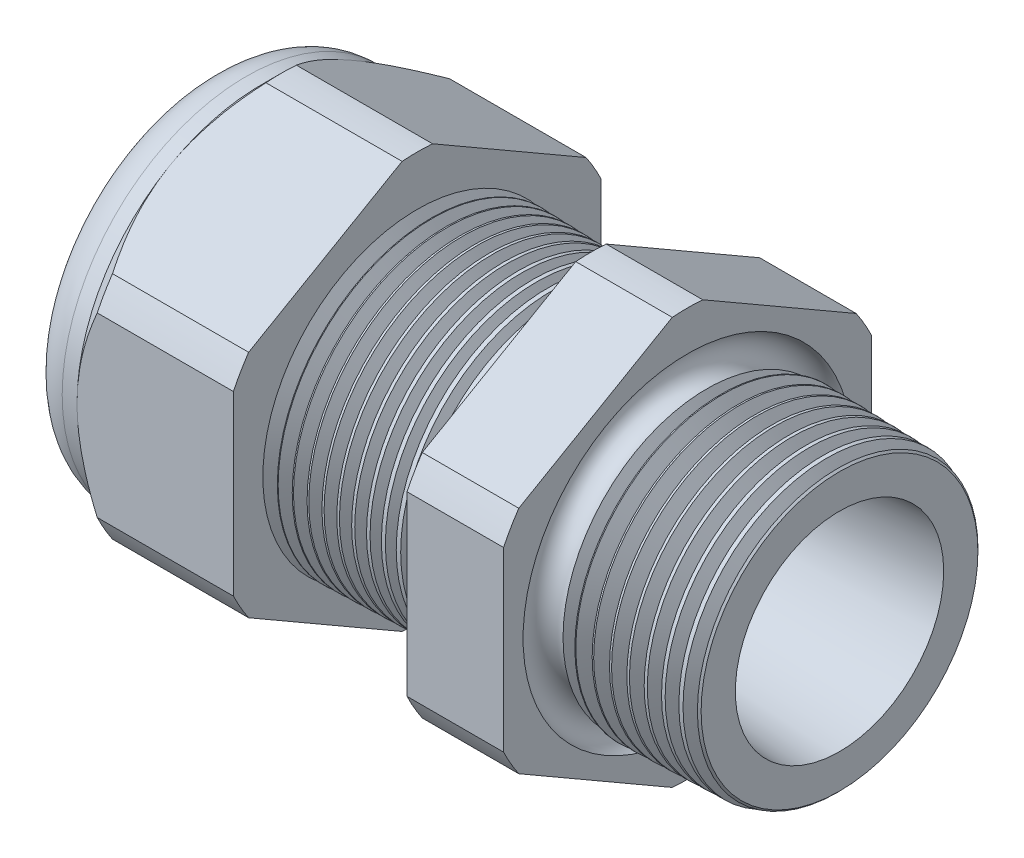
from build123d import *

# Parameters (mm, degrees)
SKETCH12_OUTSIDE_W = 52.712
SKETCH12_OUTSIDE_H = 52.712
CUT_EXTRUDE2_DEPTH = 30.966
FILLET4_R          = 2.032
SKETCH19_OUTSIDE_W = 33.73
SKETCH19_OUTSIDE_H = 35.826
SKETCH19_OUTSIDE_R = 9.525
CUT_EXTRUDE3_DEPTH = 1.999996
CUT_EXTRUDE3_DRAFT = -45
CHAMFER1_SIZE      = 0.260919487
CHAMFER1_SIZE2     = 0.254
SKETCH21_R         = 3.937
PLUG_DEPTH         = 3.81
SKETCH22_R         = 3.683
CUT_EXTRUDE4_DEPTH = 0.508
SKETCH27_R         = 1.397
PLUGHOLES_DEPTH    = 33.258
CIRPATTERN1_COUNT  = 4
LPATTERN1_COUNT    = 12
LPATTERN1_PITCH    = 0.762
LPATTERN2_COUNT    = 9
LPATTERN2_PITCH    = 0.889
SKETCH32_R         = 0.889


with BuildPart() as part:
    # Sketch10 → Revolve2 (revolve)
    with BuildSketch(Plane.XY, mode=Mode.PRIVATE) as revolve2_sk:
        Polygon((-32.766, 3.937), (-21.866, 3.937), (0, 5.396418639), (0, 7.428418639), (-7.874, 7.634606585), (-7.874, 19.05), (-12.874, 19.05), (-12.874, 7.765536193), (-21.866, 8.001), (-21.866, 19.05), (-29.966, 19.05), (-29.966, 9.525), (-32.766, 9.525), align=None)
    revolve(revolve2_sk.sketch.rotate(Axis((0, 0, 0), (-1, 0, 0)), 90), axis=Axis((0, 0, 0), (-1, 0, 0)))  # turned: the seam where the file's is

    # Sketch12 outside → Cut-Extrude2 (cut, through all)
    with BuildSketch(Plane.ZY.offset(29.966)):
        Rectangle(SKETCH12_OUTSIDE_W, SKETCH12_OUTSIDE_H)
        with BuildLine():
            Line((-0.788451287, 10.543310065), (-8.736548713, 5.954473877))
            ThreePointArc((-8.736548713, 5.954473877), (-9.156270088, 5.286375), (-9.525, 4.588836188))
            Line((-9.525, 4.588836188), (-9.525, -4.588836188))
            ThreePointArc((-9.525, -4.588836188), (-9.156270088, -5.286375), (-8.736548713, -5.954473877))
            Line((-8.736548713, -5.954473877), (-0.788451287, -10.543310065))
            ThreePointArc((-0.788451287, -10.543310065), (0, -10.57275), (0.788451287, -10.543310065))
            Line((0.788451287, -10.543310065), (8.736548713, -5.954473877))
            ThreePointArc((8.736548713, -5.954473877), (9.156270088, -5.286375), (9.525, -4.588836188))
            Line((9.525, -4.588836188), (9.525, 4.588836188))
            ThreePointArc((9.525, 4.588836188), (9.156270088, 5.286375), (8.736548713, 5.954473877))
            Line((8.736548713, 5.954473877), (0.788451287, 10.543310065))
            ThreePointArc((0.788451287, 10.543310065), (0, 10.57275), (-0.788451287, 10.543310065))
        make_face(mode=Mode.SUBTRACT)
    extrude(amount=-CUT_EXTRUDE2_DEPTH, mode=Mode.SUBTRACT)

    # Fillet4
    fillet4_edges = [part.edges().sort_by_distance(p)[0] for p in [
        (-32.766, 0, 9.525),
    ]]
    fillet(fillet4_edges, radius=FILLET4_R)


with BuildPart() as cut_extrude3_tool:
    # Sketch19 outside → Cut-Extrude3 (with draft: the straight prism first)
    with BuildSketch(Plane.ZY.offset(29.966)):
        Rectangle(SKETCH19_OUTSIDE_W, SKETCH19_OUTSIDE_H)
        Circle(SKETCH19_OUTSIDE_R, mode=Mode.SUBTRACT)
    extrude(amount=-CUT_EXTRUDE3_DEPTH)
    # Cut-Extrude3: the draft: its side faces are tilted about the plane it starts from
    cut_extrude3_sides = [cut_extrude3_tool.faces().sort_by_distance(p)[0] for p in [
        (-28.966002, -17.913, 0),
        (-28.966002, 0, 16.865),
        (-28.966002, 17.913, 0),
        (-28.966002, 0, -16.865),
        (-28.966002, 0, -9.525),
    ]]
    draft(cut_extrude3_sides, Plane.ZY.offset(29.966), CUT_EXTRUDE3_DRAFT)


with BuildPart() as part_1:
    add(part.part)

    # Cut-Extrude3: cut by cut_extrude3_tool
    add(cut_extrude3_tool.part, mode=Mode.SUBTRACT)

    # Chamfer1
    chamfer1_edges = [part_1.edges().sort_by_distance(p)[0] for p in [
        (0, 0, 7.428418639),
    ]]
    chamfer1_side = [part_1.faces().sort_by_distance(p)[0] for p in [
        (0, 0, 5.606526047),
    ]]
    chamfer(chamfer1_edges, length=CHAMFER1_SIZE, length2=CHAMFER1_SIZE2, reference=chamfer1_side[0])

    # Sketch29 → Cut-Revolve1 (revolve, cut)
    with BuildSketch(Plane.XY, mode=Mode.PRIVATE) as cut_revolve1_sk:
        Polygon((-21.866, 8.001), (-21.133016419, 7.981806149), (-21.516130572, 7.356620673), align=None)
    cut_revolve1 = revolve(cut_revolve1_sk.sketch.rotate(Axis((0, 0, 0), (-1, 0, 0)), 90), axis=Axis((0, 0, 0), (-1, 0, 0)), mode=Mode.SUBTRACT)  # turned: the seam where the file's is

    # LPattern1: Cut-Revolve1 ×12
    with Locations(*[(i * LPATTERN1_PITCH, 0, 0) for i in range(1, LPATTERN1_COUNT)]):
        add(cut_revolve1, mode=Mode.SUBTRACT)

    # Sketch30 → Cut-Revolve2 (revolve, cut)
    with BuildSketch(Plane.XY, mode=Mode.PRIVATE) as cut_revolve2_sk:
        Polygon((-7.874, 7.634606585), (-6.994419703, 7.611573965), (-7.454156686, 6.861351393), align=None)
    cut_revolve2 = revolve(cut_revolve2_sk.sketch.rotate(Axis((0, 0, 0), (-1, 0, 0)), 270), axis=Axis((0, 0, 0), (-1, 0, 0)), mode=Mode.SUBTRACT)  # turned: the seam where the file's is

    # LPattern2: Cut-Revolve2 ×9
    with Locations(*[(i * LPATTERN2_PITCH, 0, 0) for i in range(1, LPATTERN2_COUNT)]):
        add(cut_revolve2, mode=Mode.SUBTRACT)

    # Sketch32 → Cut-Revolve3 (revolve, cut)
    with BuildSketch(Plane.XY, mode=Mode.PRIVATE) as cut_revolve3_sk:
        with Locations((-7.747, 7.634606585)):
            Circle(SKETCH32_R)
    revolve(cut_revolve3_sk.sketch.rotate(Axis((0, 0, 0), (-1, 0, 0)), 270), axis=Axis((0, 0, 0), (-1, 0, 0)), mode=Mode.SUBTRACT)  # turned: the seam where the file's is


with BuildPart() as body_2:
    # Sketch21 → plug (new body)
    with BuildSketch(Plane.ZY.offset(32.766)):
        Circle(SKETCH21_R)
    extrude(amount=-PLUG_DEPTH)

    # Sketch22 → Cut-Extrude4 (cut)
    with BuildSketch(Plane.ZY.offset(32.766)):
        Circle(SKETCH22_R)
    extrude(amount=-CUT_EXTRUDE4_DEPTH, mode=Mode.SUBTRACT)

    # Sketch27 → plugholes (cut, through all)
    with BuildSketch(Plane.ZY.offset(32.258)):
        with Locations((-2.280412, 0)):
            Circle(SKETCH27_R)
    plugholes = extrude(amount=-PLUGHOLES_DEPTH, mode=Mode.SUBTRACT)

    # CirPattern1: plugholes ×4 about axis
    cirpattern1_axis = Axis((0, 0, 0), (1, 0, 0))
    for i in range(1, CIRPATTERN1_COUNT):
        add(plugholes.rotate(cirpattern1_axis, i * 360 / CIRPATTERN1_COUNT), mode=Mode.SUBTRACT)


solid = Compound([part_1.part, body_2.part])
